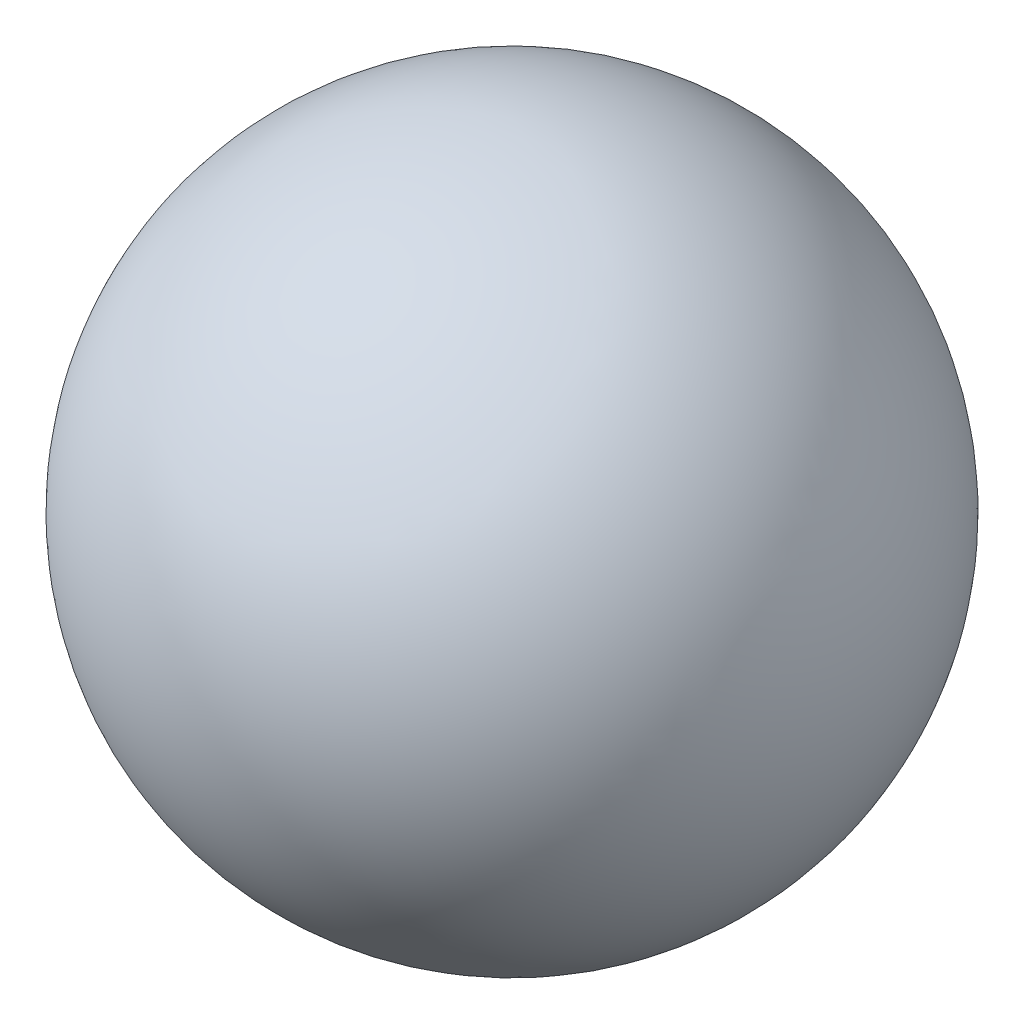
from build123d import *


with BuildPart() as part:
    # Sketch1 → Revolve1 (revolve)
    with BuildSketch(Plane(origin=(0, 0, 0), x_dir=(1, 0, 0), z_dir=(0, 1, 0))):
        with BuildLine():
            Line((-50, 0), (50, 0))
            ThreePointArc((50, 0), (0, 50), (-50, 0))
        make_face()
    revolve(axis=Axis((-50, 0, 0), (1, 0, 0)))


solid = part.part
